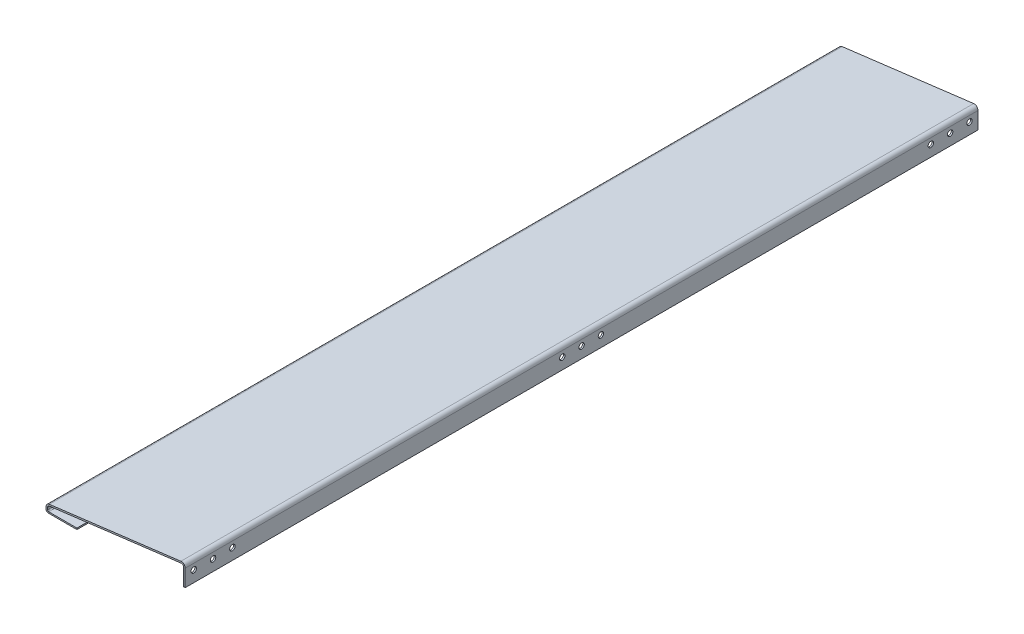
from build123d import *

# Parameters (mm, degrees)
EXTRUDE_1_DEPTH     = 2050
SHELL_1_T           = -4
CUT_EXTRUDE_1_REACH = 362
SKETCH_2_R          = 7
SKETCH_3_W          = 80
SKETCH_3_H          = 3.5
EXTRUDE_2_DEPTH     = 2050
FILLET_1_R          = 3
FILLET_2_R          = 6.5


with BuildPart() as part:
    # 草图1 → 凸台-拉伸1 (new body)
    with BuildSketch(Plane.XY):
        with BuildLine():
            Line((0, 0), (0, 43.672177815))
            ThreePointArc((0, 43.672177815), (-3.381974368, 51.168959573), (-11.240347346, 53.594956582))
            Line((-11.240347346, 53.594956582), (-351.240347346, 11.094956582))
            ThreePointArc((-351.240347346, 11.094956582), (-357.496781758, 7.790203447), (-360, 1.172177815))
            Line((-360, 1.172177815), (-360, -10))
            Line((-360, -10), (-300, -10))
            Line((-300, -10), (0, 0))
        make_face()
    extrude(amount=EXTRUDE_1_DEPTH)

    # 抽壳1
    shell_1_openings = [part.faces().sort_by_distance(p)[0] for p in [
        (-197.44558621, 13.389471059, 2050),
        (-330, -10, 1025),
        (-150, -5, 1025),
        (-197.44558621, 13.389471059, 0),
    ]]
    offset(amount=SHELL_1_T, openings=shell_1_openings, kind=Kind.INTERSECTION)

    # 草图2 → 切除-拉伸1 (cut, up to next)
    with BuildSketch(Plane(origin=(0, 0, 0), x_dir=(0, 0, -1), z_dir=(1, 0, 0)), mode=Mode.PRIVATE) as cut_extrude_1_sk1:
        with Locations((-2028, 28.672177815)):
            Circle(SKETCH_2_R)
    cut_extrude_1_tool1 = extrude(cut_extrude_1_sk1.sketch, amount=-CUT_EXTRUDE_1_REACH, mode=Mode.PRIVATE) & part.part
    add(cut_extrude_1_tool1.solids().sort_by_distance((0, 28.672178, 2028))[0], mode=Mode.SUBTRACT)
    # 草图2 → 切除-拉伸1 (cut, up to next)
    with BuildSketch(Plane(origin=(0, 0, 0), x_dir=(0, 0, -1), z_dir=(1, 0, 0)), mode=Mode.PRIVATE) as cut_extrude_1_sk2:
        with Locations((-1978, 28.672177815)):
            Circle(SKETCH_2_R)
    cut_extrude_1_tool2 = extrude(cut_extrude_1_sk2.sketch, amount=-CUT_EXTRUDE_1_REACH, mode=Mode.PRIVATE) & part.part
    add(cut_extrude_1_tool2.solids().sort_by_distance((0, 28.672178, 1978))[0], mode=Mode.SUBTRACT)
    # 草图2 → 切除-拉伸1 (cut, up to next)
    with BuildSketch(Plane(origin=(0, 0, 0), x_dir=(0, 0, -1), z_dir=(1, 0, 0)), mode=Mode.PRIVATE) as cut_extrude_1_sk3:
        with Locations((-1928, 28.672177815)):
            Circle(SKETCH_2_R)
    cut_extrude_1_tool3 = extrude(cut_extrude_1_sk3.sketch, amount=-CUT_EXTRUDE_1_REACH, mode=Mode.PRIVATE) & part.part
    add(cut_extrude_1_tool3.solids().sort_by_distance((0, 28.672178, 1928))[0], mode=Mode.SUBTRACT)
    # 草图2 → 切除-拉伸1 (cut, up to next)
    with BuildSketch(Plane(origin=(0, 0, 0), x_dir=(0, 0, -1), z_dir=(1, 0, 0)), mode=Mode.PRIVATE) as cut_extrude_1_sk4:
        with Locations((-122, 28.672177815)):
            Circle(SKETCH_2_R)
    cut_extrude_1_tool4 = extrude(cut_extrude_1_sk4.sketch, amount=-CUT_EXTRUDE_1_REACH, mode=Mode.PRIVATE) & part.part
    add(cut_extrude_1_tool4.solids().sort_by_distance((0, 28.672178, 122))[0], mode=Mode.SUBTRACT)
    # 草图2 → 切除-拉伸1 (cut, up to next)
    with BuildSketch(Plane(origin=(0, 0, 0), x_dir=(0, 0, -1), z_dir=(1, 0, 0)), mode=Mode.PRIVATE) as cut_extrude_1_sk5:
        with Locations((-72, 28.672177815)):
            Circle(SKETCH_2_R)
    cut_extrude_1_tool5 = extrude(cut_extrude_1_sk5.sketch, amount=-CUT_EXTRUDE_1_REACH, mode=Mode.PRIVATE) & part.part
    add(cut_extrude_1_tool5.solids().sort_by_distance((0, 28.672178, 72))[0], mode=Mode.SUBTRACT)
    # 草图2 → 切除-拉伸1 (cut, up to next)
    with BuildSketch(Plane(origin=(0, 0, 0), x_dir=(0, 0, -1), z_dir=(1, 0, 0)), mode=Mode.PRIVATE) as cut_extrude_1_sk6:
        with Locations((-22, 28.672177815)):
            Circle(SKETCH_2_R)
    cut_extrude_1_tool6 = extrude(cut_extrude_1_sk6.sketch, amount=-CUT_EXTRUDE_1_REACH, mode=Mode.PRIVATE) & part.part
    add(cut_extrude_1_tool6.solids().sort_by_distance((0, 28.672178, 22))[0], mode=Mode.SUBTRACT)
    # 草图2 → 切除-拉伸1 (cut, up to next)
    with BuildSketch(Plane(origin=(0, 0, 0), x_dir=(0, 0, -1), z_dir=(1, 0, 0)), mode=Mode.PRIVATE) as cut_extrude_1_sk7:
        with Locations((-1025, 28.672177815)):
            Circle(SKETCH_2_R)
    cut_extrude_1_tool7 = extrude(cut_extrude_1_sk7.sketch, amount=-CUT_EXTRUDE_1_REACH, mode=Mode.PRIVATE) & part.part
    add(cut_extrude_1_tool7.solids().sort_by_distance((0, 28.672178, 1025))[0], mode=Mode.SUBTRACT)
    # 草图2 → 切除-拉伸1 (cut, up to next)
    with BuildSketch(Plane(origin=(0, 0, 0), x_dir=(0, 0, -1), z_dir=(1, 0, 0)), mode=Mode.PRIVATE) as cut_extrude_1_sk8:
        with Locations((-1075, 28.672177815)):
            Circle(SKETCH_2_R)
    cut_extrude_1_tool8 = extrude(cut_extrude_1_sk8.sketch, amount=-CUT_EXTRUDE_1_REACH, mode=Mode.PRIVATE) & part.part
    add(cut_extrude_1_tool8.solids().sort_by_distance((0, 28.672178, 1075))[0], mode=Mode.SUBTRACT)
    # 草图2 → 切除-拉伸1 (cut, up to next)
    with BuildSketch(Plane(origin=(0, 0, 0), x_dir=(0, 0, -1), z_dir=(1, 0, 0)), mode=Mode.PRIVATE) as cut_extrude_1_sk9:
        with Locations((-975, 28.672177815)):
            Circle(SKETCH_2_R)
    cut_extrude_1_tool9 = extrude(cut_extrude_1_sk9.sketch, amount=-CUT_EXTRUDE_1_REACH, mode=Mode.PRIVATE) & part.part
    add(cut_extrude_1_tool9.solids().sort_by_distance((0, 28.672178, 975))[0], mode=Mode.SUBTRACT)

    # 草图3 → 凸台-拉伸2 (add)
    with BuildSketch(Plane.XY.offset(2050)):
        with Locations((-320, -8.25)):
            Rectangle(SKETCH_3_W, SKETCH_3_H)
    extrude(amount=-EXTRUDE_2_DEPTH)

    # 圆角1
    fillet_1_edges = [part.edges().sort_by_distance(p)[0] for p in [
        (-356, -6.5, 1025),
    ]]
    fillet(fillet_1_edges, radius=FILLET_1_R)

    # 圆角2
    fillet_2_edges = [part.edges().sort_by_distance(p)[0] for p in [
        (-360, -10, 1025),
    ]]
    fillet(fillet_2_edges, radius=FILLET_2_R)


solid = part.part
